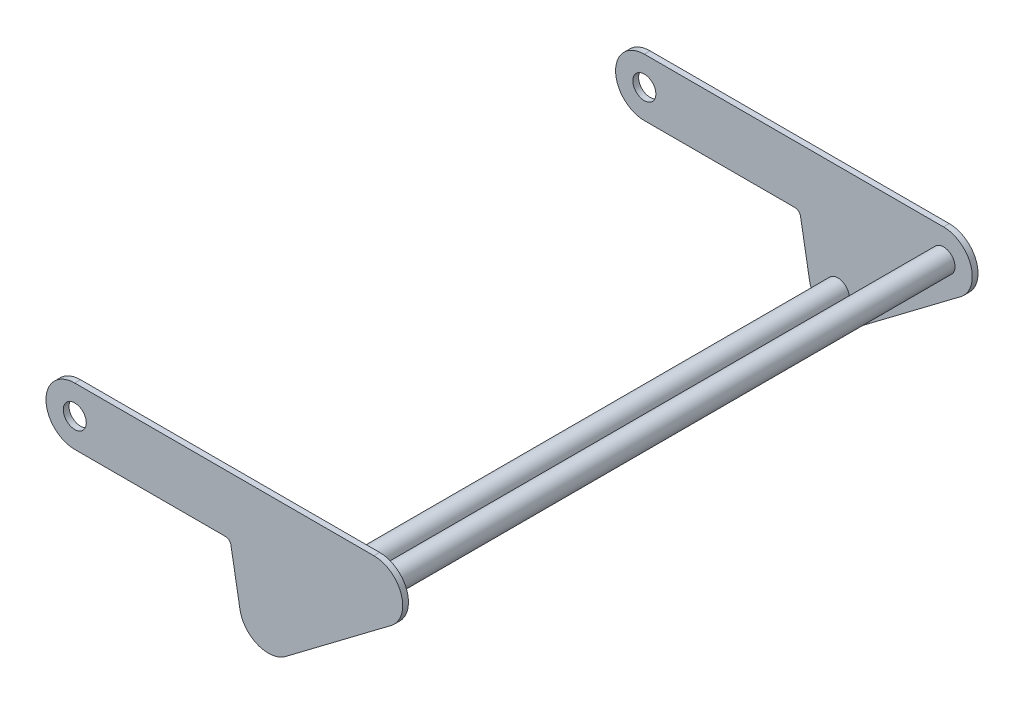
from build123d import *

# Parameters (mm, degrees)
SKETCH1_R                       = 12.7
BOSS_EXTRUDE1_DEPTH             = 317.5
SKETCH2_W                       = 393.7
SKETCH2_H                       = 622.3
CUT_EXTRUDE1_DEPTH              = 152.447724951
BOSS_EXTRUDE2_REACH             = 319.5
SKETCH3_R                       = 12.7
BOSS_EXTRUDE2_DIRECTION_2_REACH = 319.5


with BuildPart() as part:
    # Sketch1 → Boss-Extrude1 (new body, symmetric)
    with BuildSketch(Plane.XY):
        with BuildLine():
            Line((0, 0), (166.121717342, 0))
            ThreePointArc((166.121717342, 0), (170.203418664, -1.485617786), (172.375246574, -5.247334072))
            Line((172.375246574, -5.247334072), (182.331323933, -61.711054592))
            ThreePointArc((182.331323933, -61.711054592), (201.969223554, -85.741108229), (232.718040732, -81.545774931))
            Line((232.718040732, -81.545774931), (349.319070642, 6.40195002))
            ThreePointArc((349.319070642, 6.40195002), (360.307001568, 41.83121801), (330.2, 63.5))
            Line((330.2, 63.5), (0, 63.5))
            ThreePointArc((0, 63.5), (-31.75, 31.75), (0, 0))
        make_face()
        with Locations((0, 31.75)):
            Circle(SKETCH1_R, mode=Mode.SUBTRACT)
    extrude(amount=BOSS_EXTRUDE1_DEPTH, both=True)

    # Sketch2 → Cut-Extrude1 (cut, through all)
    with BuildSketch(Plane(origin=(0, 63.5, 0), x_dir=(1, 0, 0), z_dir=(0, 1, 0))):
        with Locations((165.1, 0)):
            Rectangle(SKETCH2_W, SKETCH2_H)
    extrude(amount=-CUT_EXTRUDE1_DEPTH, mode=Mode.SUBTRACT)

    # Sketch3 → Boss-Extrude2 (add, up to next)
    with BuildSketch(Plane.XY, mode=Mode.PRIVATE) as boss_extrude2_sk1:
        with Locations((330.2, 31.75)):
            Circle(SKETCH3_R)
    boss_extrude2_tool1 = extrude(boss_extrude2_sk1.sketch, amount=BOSS_EXTRUDE2_REACH, mode=Mode.PRIVATE) - part.part
    add(boss_extrude2_tool1.solids().sort_by_distance((330.2, 31.75, 0))[0])
    # Sketch3 → Boss-Extrude2 (add, up to next)
    with BuildSketch(Plane.XY, mode=Mode.PRIVATE) as boss_extrude2_sk2:
        with Locations((213.598970091, -56.197724951)):
            Circle(SKETCH3_R)
    boss_extrude2_tool2 = extrude(boss_extrude2_sk2.sketch, amount=BOSS_EXTRUDE2_REACH, mode=Mode.PRIVATE) - part.part
    add(boss_extrude2_tool2.solids().sort_by_distance((213.59897, -56.197725, 0))[0])

    # Sketch3 → Boss-Extrude2 direction 2 (add, up to next)
    with BuildSketch(Plane.XY, mode=Mode.PRIVATE) as boss_extrude2_direction_2_sk1:
        with Locations((330.2, 31.75)):
            Circle(SKETCH3_R)
    boss_extrude2_direction_2_tool1 = extrude(boss_extrude2_direction_2_sk1.sketch, amount=-BOSS_EXTRUDE2_DIRECTION_2_REACH, mode=Mode.PRIVATE) - part.part
    add(boss_extrude2_direction_2_tool1.solids().sort_by_distance((330.2, 31.75, 0))[0])
    # Sketch3 → Boss-Extrude2 direction 2 (add, up to next)
    with BuildSketch(Plane.XY, mode=Mode.PRIVATE) as boss_extrude2_direction_2_sk2:
        with Locations((213.598970091, -56.197724951)):
            Circle(SKETCH3_R)
    boss_extrude2_direction_2_tool2 = extrude(boss_extrude2_direction_2_sk2.sketch, amount=-BOSS_EXTRUDE2_DIRECTION_2_REACH, mode=Mode.PRIVATE) - part.part
    add(boss_extrude2_direction_2_tool2.solids().sort_by_distance((213.59897, -56.197725, 0))[0])


solid = part.part
